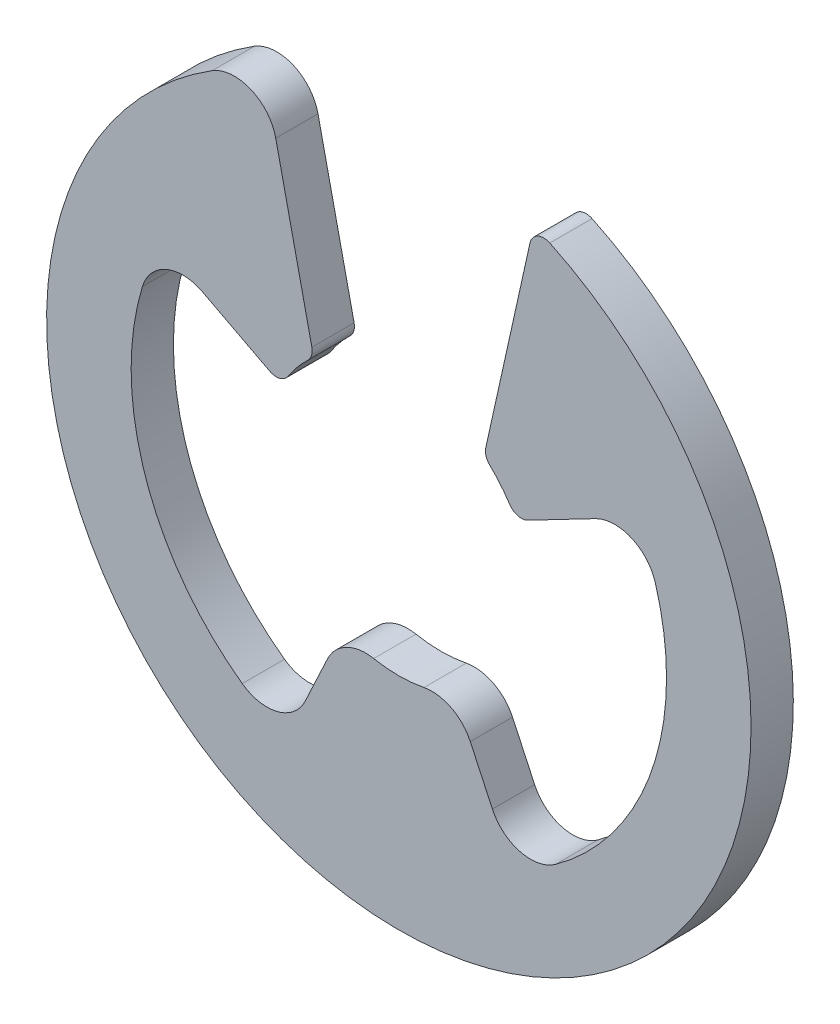
from build123d import *
from OCP.BRepFilletAPI import BRepFilletAPI_MakeFillet

# Parameters (mm, degrees)
SKETCH1_R           = 3.175
SKETCH1_R_2         = 1.190625
BOSS_EXTRUDE1_DEPTH = 0.1905
CUT_EXTRUDE1_DEPTH  = 5.50626353
CUT_EXTRUDE2_DEPTH  = 5.50626353
FILLET1_R1          = 0.381
FILLET1_R2          = 0.127


with BuildPart() as part:
    # Sketch1 → Boss-Extrude1 (new, symmetric)
    with BuildSketch(Plane.XY):
        Circle(SKETCH1_R)
        Circle(SKETCH1_R_2, mode=Mode.SUBTRACT)
    extrude(amount=BOSS_EXTRUDE1_DEPTH, both=True)

    # Sketch2 → Cut-Extrude1 (cut, through all)
    with BuildSketch(Plane.XY.offset(0.1905)):
        with BuildLine():
            Line((-1.216302436, 2.932785942), (-0.767848913, 0.909942821))
            ThreePointArc((-0.767848913, 0.909942821), (0, 1.190625), (0.767848913, 0.909942821))
            Line((0.767848913, 0.909942821), (1.216302436, 2.932785942))
            ThreePointArc((1.216302436, 2.932785942), (0, 3.175), (-1.216302436, 2.932785942))
        make_face()
    extrude(amount=-CUT_EXTRUDE1_DEPTH, mode=Mode.SUBTRACT)

    # Sketch3 → Cut-Extrude2 (cut, through all)
    with BuildSketch(Plane.XY.offset(0.1905)):
        with BuildLine():
            Line((-1.056097273, 0.549769443), (-2.14035714, 1.114199404))
            ThreePointArc((-2.14035714, 1.114199404), (-2.284896317, -0.775769179), (-1.019518005, -2.187041846))
            Line((-1.019518005, -2.187041846), (-0.50292, -1.079193849))
            ThreePointArc((-0.50292, -1.079193849), (-1.127392596, -0.382849611), (-1.056097273, 0.549769443))
        make_face()
        with BuildLine():
            Line((0.50292, -1.079193849), (1.019518005, -2.187041846))
            ThreePointArc((1.019518005, -2.187041846), (2.284896317, -0.775769179), (2.14035714, 1.114199404))
            Line((2.14035714, 1.114199404), (1.056097273, 0.549769443))
            ThreePointArc((1.056097273, 0.549769443), (1.127392596, -0.382849611), (0.50292, -1.079193849))
        make_face()
    extrude(amount=-CUT_EXTRUDE2_DEPTH, mode=Mode.SUBTRACT)

    # Fillet1: one fillet with a radius per group of edges: ONE call of the kernel's fillet builder (fillet() takes one radius for all edges)
    fillet1_edges_1 = [part.edges().sort_by_distance(p)[0] for p in [
        (-1.216302436, 2.932785942, 0),
        (-2.14035714, 1.114199404, 0),
        (-1.019518005, -2.187041846, 0),
        (-0.50292, -1.079193849, 0),
        (0.50292, -1.079193849, 0),
        (1.019518005, -2.187041846, 0),
        (2.14035714, 1.114199404, 0),
    ]]
    fillet1_edges_2 = [part.edges().sort_by_distance(p)[0] for p in [
        (1.216302436, 2.932785942, 0),
        (-0.767848913, 0.909942821, 0),
        (-1.056097273, 0.549769443, 0),
        (1.056097273, 0.549769443, 0),
        (0.767848913, 0.909942821, 0),
    ]]
    fillet1 = BRepFilletAPI_MakeFillet(part.part.solid().wrapped)
    for e in fillet1_edges_1:
        fillet1.Add(FILLET1_R1, e.wrapped)
    for e in fillet1_edges_2:
        fillet1.Add(FILLET1_R2, e.wrapped)
    add(Compound.cast(fillet1.Shape()), mode=Mode.REPLACE)


solid = part.part
